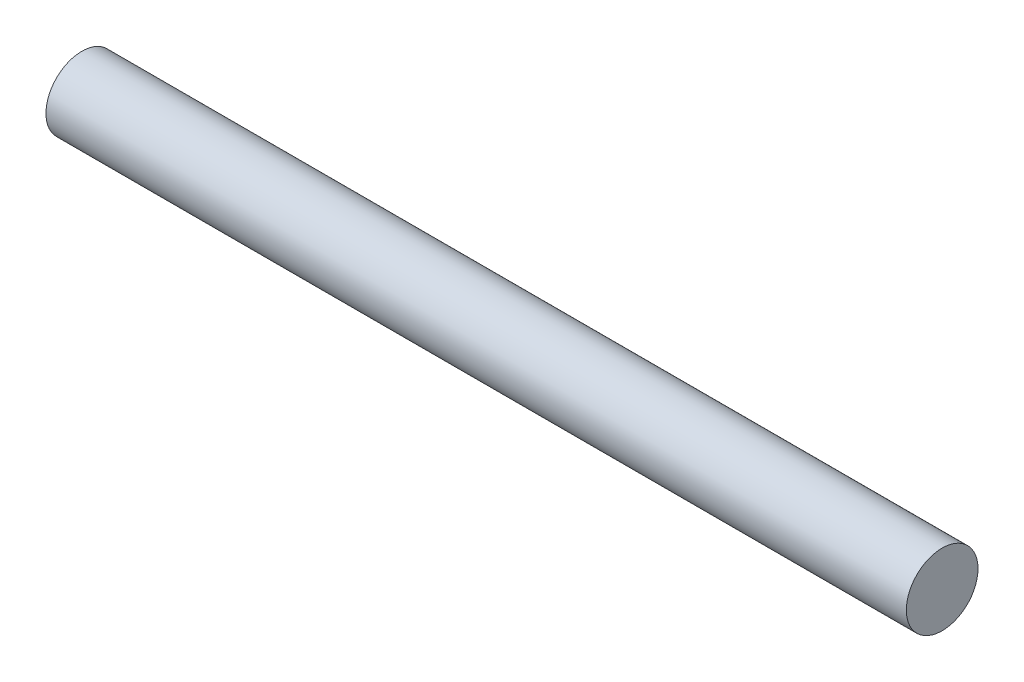
from build123d import *

# Parameters (mm, degrees)
SKETCH1_R           = 4
BOSS_EXTRUDE1_DEPTH = 96


with BuildPart() as part:
    # Sketch1 → Boss-Extrude1 (new body)
    with BuildSketch(Plane(origin=(0, 0, 0), x_dir=(0, 0, -1), z_dir=(1, 0, 0))):
        Circle(SKETCH1_R)
    extrude(amount=BOSS_EXTRUDE1_DEPTH)


solid = part.part
